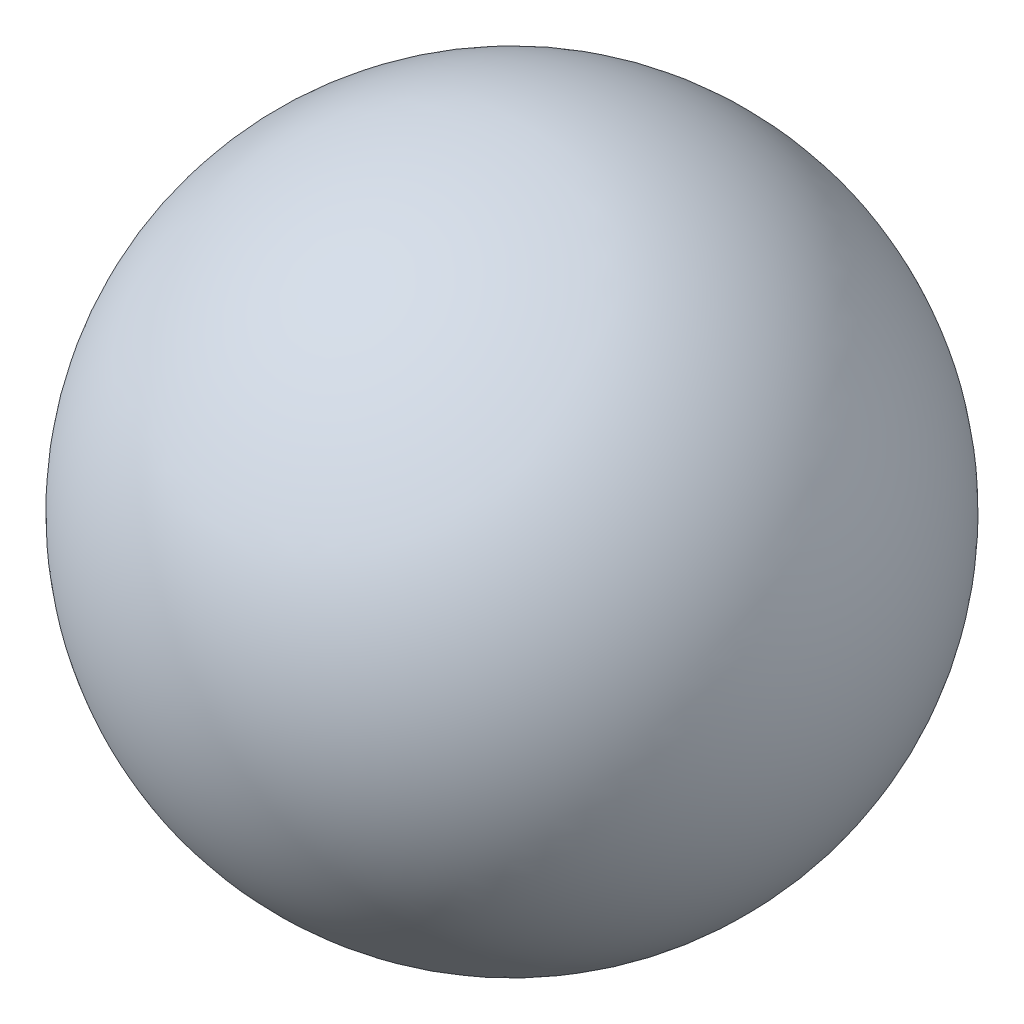
from build123d import *


with BuildPart() as part:
    # Sketch1 → Revolve1 (revolve)
    with BuildSketch(Plane(origin=(0, 0, 0), x_dir=(1, 0, 0), z_dir=(0, 1, 0))):
        with BuildLine():
            Line((0, 30), (0, -30))
            ThreePointArc((0, -30), (-30, 0), (0, 30))
        make_face()
    revolve(axis=Axis((0, 0, -30), (0, 0, 1)))


solid = part.part
